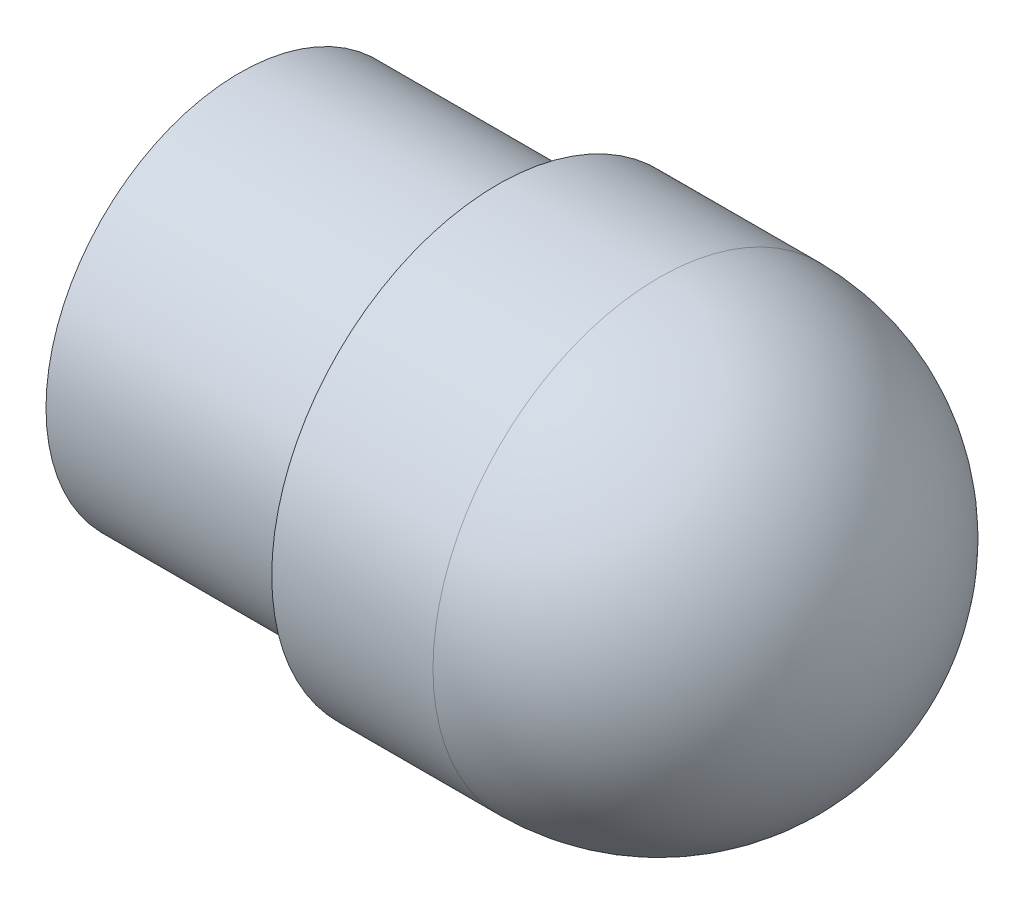
from build123d import *


with BuildPart() as part:
    # Croquis1 → Revolución1 (revolve)
    with BuildSketch(Plane.XY):
        with BuildLine():
            Line((0, 0), (50, 0))
            ThreePointArc((50, 0), (44.874368671, 12.374368671), (32.5, 17.5))
            Line((32.5, 17.5), (20, 17.5))
            Line((20, 17.5), (20, 15))
            Line((20, 15), (0, 15))
            Line((0, 15), (0, 0))
        make_face()
    revolve(axis=Axis((0, 0, 0), (1, 0, 0)))


solid = part.part
